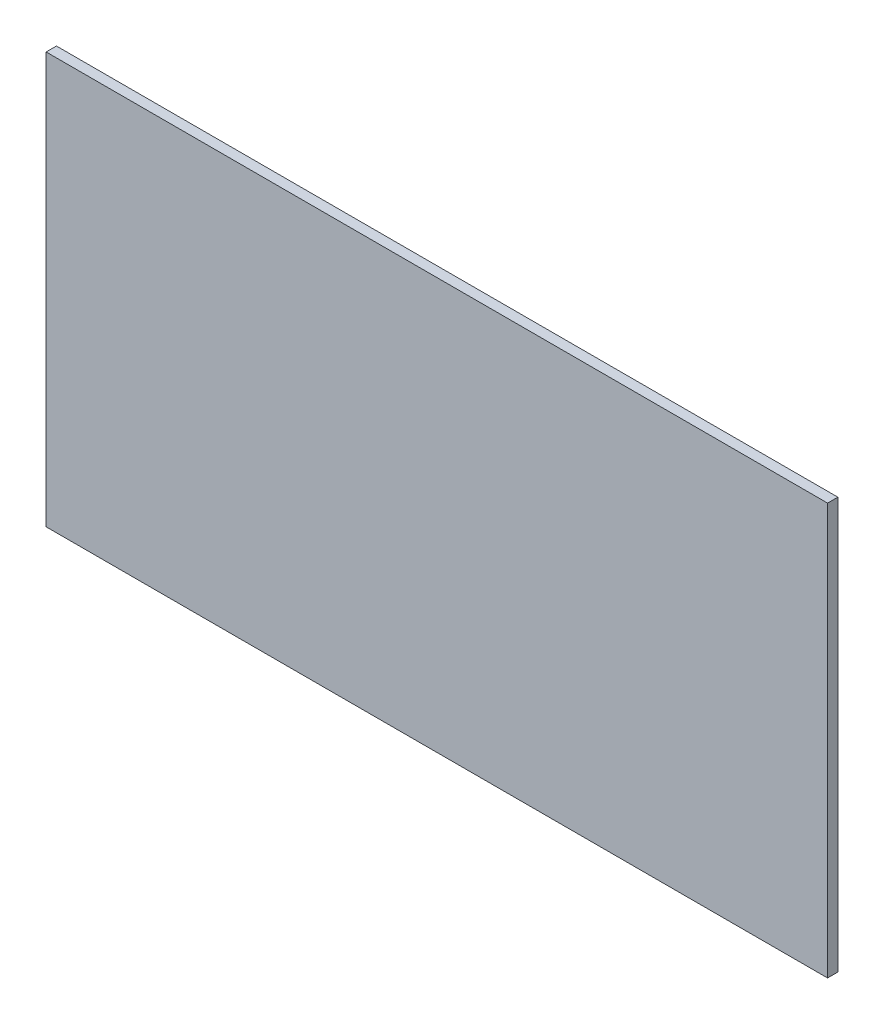
from build123d import *

# Parameters (mm, degrees)
SKETCH1_W           = 3.175
SKETCH1_H           = 127
BOSS_EXTRUDE1_DEPTH = 241.3


with BuildPart() as part:
    # Sketch1 → Boss-Extrude1 (new body)
    with BuildSketch(Plane(origin=(0, 0, 0), x_dir=(0, 0, -1), z_dir=(1, 0, 0))):
        with Locations((1.5875, 63.5)):
            Rectangle(SKETCH1_W, SKETCH1_H)
    extrude(amount=BOSS_EXTRUDE1_DEPTH)


solid = part.part
